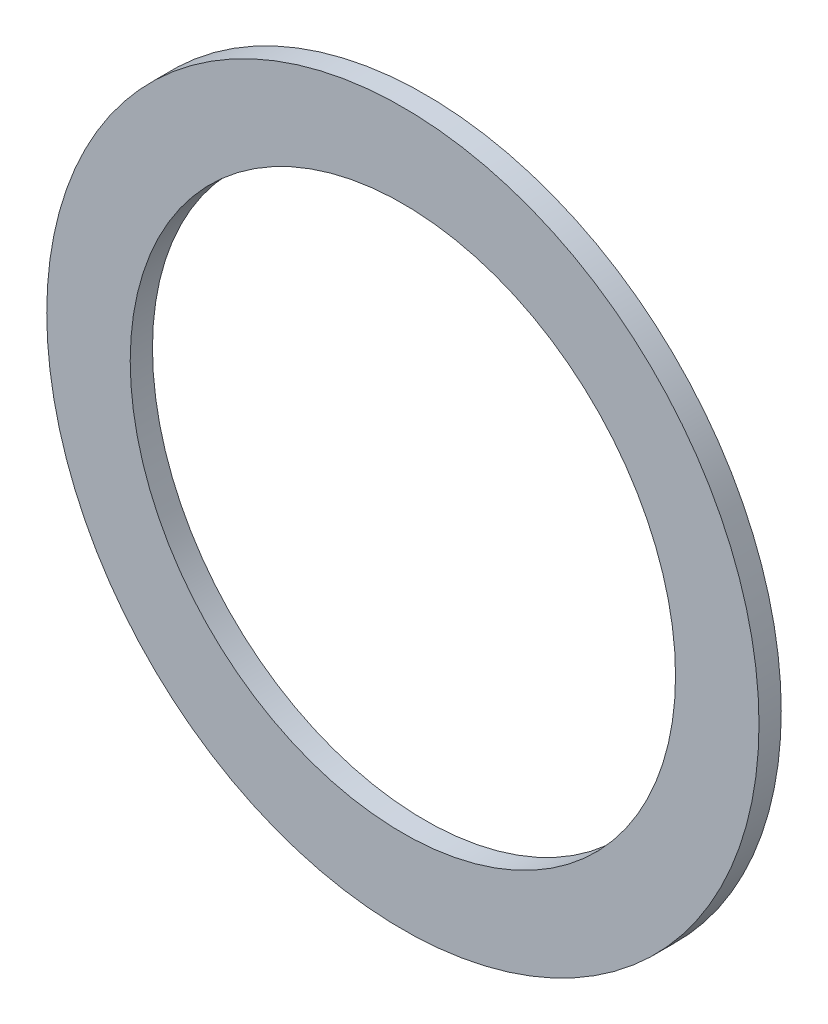
from build123d import *

# Parameters (mm, degrees)
SKETCH1_R           = 16
SKETCH1_R_2         = 12.25
BOSS_EXTRUDE1_DEPTH = 1


with BuildPart() as part:
    # Sketch1 → Boss-Extrude1 (new body)
    with BuildSketch(Plane.XY):
        Circle(SKETCH1_R)
        Circle(SKETCH1_R_2, mode=Mode.SUBTRACT)
    extrude(amount=BOSS_EXTRUDE1_DEPTH)


solid = part.part
